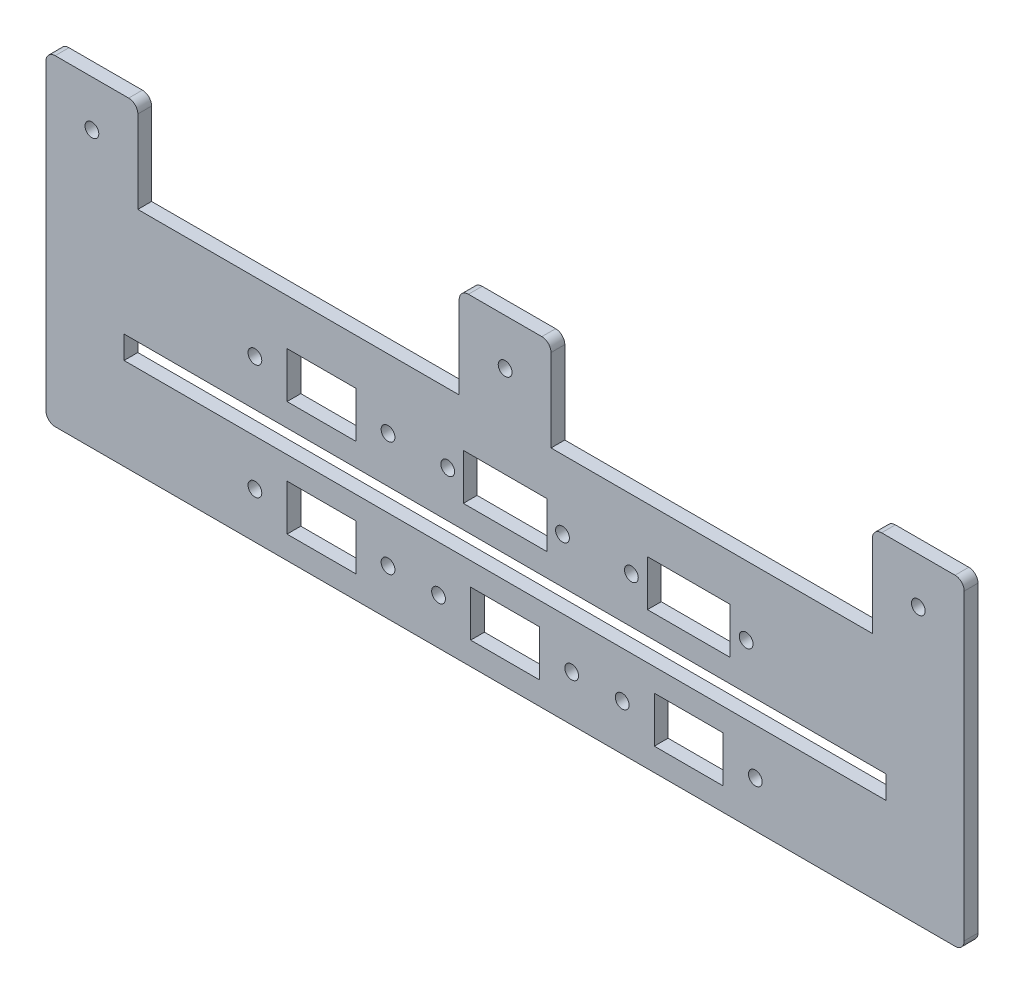
from build123d import *

# Parameters (mm, degrees)
SKETCH_1_W           = 200
SKETCH_1_H           = 70
EXTRUDE_1_DEPTH      = 3
SKETCH_2_W           = 70
SKETCH_2_H           = 20
CUT_EXTRUDE_1_DEPTH  = 3
SKETCH_4_W           = 70
SKETCH_4_H           = 20
CUT_EXTRUDE_2_DEPTH  = 3
SKETCH_5_W           = 166
SKETCH_5_H           = 5
CUT_EXTRUDE_3_DEPTH  = 3
CUT_EXTRUDE_8_DEPTH  = 3
SKETCH_7_R           = 1.5
CUT_EXTRUDE_9_DEPTH  = 3
SKETCH_8_W           = 15
SKETCH_8_H           = 10
CUT_EXTRUDE_10_DEPTH = 3
SKETCH_9_W           = 15
SKETCH_9_H           = 10
SKETCH_9_W_2         = 18
SKETCH_9_W_3         = 18.2
CUT_EXTRUDE_11_DEPTH = 3
SKETCH_10_R          = 1.5
CUT_EXTRUDE_12_DEPTH = 3


with BuildPart() as part:
    # ｽｹｯﾁ1 → ﾎﾞｽ - 押し出し1 (new body)
    with BuildSketch(Plane.XY):
        Rectangle(SKETCH_1_W, SKETCH_1_H)
    extrude(amount=EXTRUDE_1_DEPTH)

    # ｽｹｯﾁ2 → ｶｯﾄ - 押し出し1 (cut)
    with BuildSketch(Plane.XY.offset(3)):
        with Locations((-45, 25)):
            Rectangle(SKETCH_2_W, SKETCH_2_H)
    extrude(amount=-CUT_EXTRUDE_1_DEPTH, mode=Mode.SUBTRACT)

    # ｽｹｯﾁ4 → ｶｯﾄ - 押し出し2 (cut)
    with BuildSketch(Plane.XY.offset(3)):
        with Locations((45, 25)):
            Rectangle(SKETCH_4_W, SKETCH_4_H)
    extrude(amount=-CUT_EXTRUDE_2_DEPTH, mode=Mode.SUBTRACT)

    # ｽｹｯﾁ5 → ｶｯﾄ - 押し出し3 (cut)
    with BuildSketch(Plane.XY.offset(3)):
        with Locations((0, -12.5)):
            Rectangle(SKETCH_5_W, SKETCH_5_H)
    extrude(amount=-CUT_EXTRUDE_3_DEPTH, mode=Mode.SUBTRACT)

    # ｽｹｯﾁ6 → ｶｯﾄ - 押し出し8 (cut)
    with BuildSketch(Plane.XY.offset(3)):
        with BuildLine():
            ThreePointArc((-98, -35), (-99.414213562, -34.414213562), (-100, -33))
            Line((-100, -33), (-100, -35))
            Line((-100, -35), (-98, -35))
        make_face()
        with BuildLine():
            Line((-100, 35), (-100, 33))
            ThreePointArc((-100, 33), (-99.414213562, 34.414213562), (-98, 35))
            Line((-98, 35), (-100, 35))
        make_face()
        with BuildLine():
            ThreePointArc((100, -33), (99.414213562, -34.414213562), (98, -35))
            Line((98, -35), (100, -35))
            Line((100, -35), (100, -33))
        make_face()
        with BuildLine():
            Line((-80, 35), (-82, 35))
            ThreePointArc((-82, 35), (-80.585786438, 34.414213562), (-80, 33))
            Line((-80, 33), (-80, 35))
        make_face()
        with BuildLine():
            ThreePointArc((98, 35), (99.414213562, 34.414213562), (100, 33))
            Line((100, 33), (100, 35))
            Line((100, 35), (98, 35))
        make_face()
        with BuildLine():
            ThreePointArc((80, 33), (80.585786438, 34.414213562), (82, 35))
            Line((82, 35), (80, 35))
            Line((80, 35), (80, 33))
        make_face()
        with BuildLine():
            Line((-10, 35), (-10, 33))
            ThreePointArc((-10, 33), (-9.414213562, 34.414213562), (-8, 35))
            Line((-8, 35), (-10, 35))
        make_face()
        with BuildLine():
            Line((10, 35), (8, 35))
            ThreePointArc((8, 35), (9.414213562, 34.414213562), (10, 33))
            Line((10, 33), (10, 35))
        make_face()
    extrude(amount=-CUT_EXTRUDE_8_DEPTH, mode=Mode.SUBTRACT)

    # ｽｹｯﾁ7 → ｶｯﾄ - 押し出し9 (cut)
    with BuildSketch(Plane.XY.offset(3)):
        with Locations((-90, 25)):
            Circle(SKETCH_7_R)
        with Locations((0, 25)):
            Circle(SKETCH_7_R)
        with Locations((90, 25)):
            Circle(SKETCH_7_R)
    extrude(amount=-CUT_EXTRUDE_9_DEPTH, mode=Mode.SUBTRACT)

    # ｽｹｯﾁ8 → ｶｯﾄ - 押し出し10 (cut)
    with BuildSketch(Plane.XY.offset(3)):
        with Locations((40, -25)):
            Rectangle(SKETCH_8_W, SKETCH_8_H)
        with Locations((0, -25)):
            Rectangle(SKETCH_8_W, SKETCH_8_H)
        with Locations((-40, -25)):
            Rectangle(SKETCH_8_W, SKETCH_8_H)
    extrude(amount=-CUT_EXTRUDE_10_DEPTH, mode=Mode.SUBTRACT)

    # ｽｹｯﾁ9 → ｶｯﾄ - 押し出し11 (cut)
    with BuildSketch(Plane.XY.offset(3)):
        with Locations((-40, 0)):
            Rectangle(SKETCH_9_W, SKETCH_9_H)
        with Locations((40, 0)):
            Rectangle(SKETCH_9_W_2, SKETCH_9_H)
        Rectangle(SKETCH_9_W_3, SKETCH_9_H)
    extrude(amount=-CUT_EXTRUDE_11_DEPTH, mode=Mode.SUBTRACT)

    # ｽｹｯﾁ10 → ｶｯﾄ - 押し出し12 (cut)
    with BuildSketch(Plane.XY.offset(3)):
        with Locations((-54.5, 0)):
            Circle(SKETCH_10_R)
        with Locations((-25.5, 0)):
            Circle(SKETCH_10_R)
        with Locations((-12.5, 0)):
            Circle(SKETCH_10_R)
        with Locations((12.5, 0)):
            Circle(SKETCH_10_R)
        with Locations((27.5, 0)):
            Circle(SKETCH_10_R)
        with Locations((52.5, 0)):
            Circle(SKETCH_10_R)
        with Locations((54.5, -25)):
            Circle(SKETCH_10_R)
        with Locations((25.5, -25)):
            Circle(SKETCH_10_R)
        with Locations((14.5, -25)):
            Circle(SKETCH_10_R)
        with Locations((-14.5, -25)):
            Circle(SKETCH_10_R)
        with Locations((-25.5, -25)):
            Circle(SKETCH_10_R)
        with Locations((-54.5, -25)):
            Circle(SKETCH_10_R)
    extrude(amount=-CUT_EXTRUDE_12_DEPTH, mode=Mode.SUBTRACT)


solid = part.part
